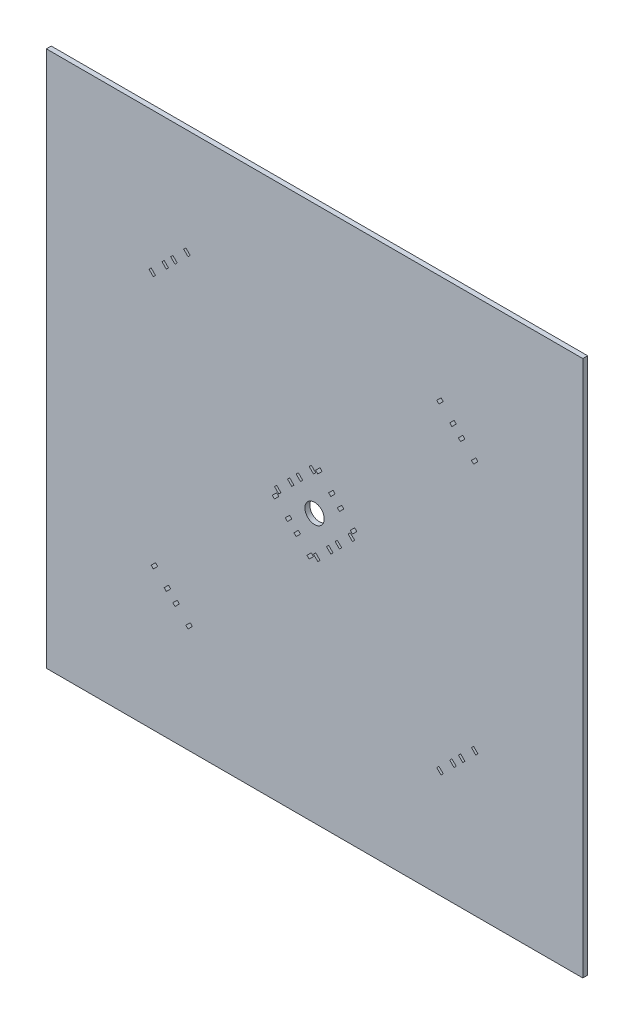
from build123d import *

# Parameters (mm, degrees)
MODEL_W             = 175
MODEL_H             = 175
MODEL_R             = 3.15
BOSS_EXTRUDE1_DEPTH = 1.5875


with BuildPart() as part:
    # Model → Boss-Extrude1 (new body)
    with BuildSketch(Plane.XY):
        with Locations((87.5, 87.5)):
            Rectangle(MODEL_W, MODEL_H)
        with Locations((87.5, 87.5)):
            Circle(MODEL_R, mode=Mode.SUBTRACT)
        Polygon((139.381727984, 47.639087297), (140.795941546, 46.224873734), (140.088834765, 45.517766953), (138.674621202, 46.931980515), align=None, mode=Mode.SUBTRACT)
        Polygon((135.139087297, 43.396446609), (136.553300859, 41.982233047), (135.846194078, 41.275126266), (134.431980515, 42.689339828), align=None, mode=Mode.SUBTRACT)
        Polygon((132.310660172, 40.568019485), (133.724873734, 39.153805922), (133.017766953, 38.446699141), (131.603553391, 39.860912703), align=None, mode=Mode.SUBTRACT)
        Polygon((128.068019485, 36.325378798), (129.482233047, 34.911165235), (128.775126266, 34.204058454), (127.360912703, 35.618272016), align=None, mode=Mode.SUBTRACT)
        Polygon((87.853553391, 76.539844892), (89.267766953, 75.125631329), (88.560660172, 74.418524548), (87.146446609, 75.83273811), align=None, mode=Mode.SUBTRACT)
        Polygon((92.096194078, 80.782485579), (93.51040764, 79.368272016), (92.803300859, 78.661165235), (91.389087297, 80.075378798), align=None, mode=Mode.SUBTRACT)
        Polygon((47.639087297, 35.618272016), (46.224873734, 34.204058454), (45.517766953, 34.911165235), (46.931980515, 36.325378798), align=None, mode=Mode.SUBTRACT)
        Polygon((43.396446609, 39.860912703), (41.982233047, 38.446699141), (41.275126266, 39.153805922), (42.689339828, 40.568019485), align=None, mode=Mode.SUBTRACT)
        Polygon((40.568019485, 42.689339828), (39.153805922, 41.275126266), (38.446699141, 41.982233047), (39.860912703, 43.396446609), align=None, mode=Mode.SUBTRACT)
        Polygon((36.325378798, 46.931980515), (34.911165235, 45.517766953), (34.204058454, 46.224873734), (35.618272016, 47.639087297), align=None, mode=Mode.SUBTRACT)
        Polygon((75.83273811, 86.439339828), (74.418524548, 85.025126266), (73.711417767, 85.732233047), (75.125631329, 87.146446609), align=None, mode=Mode.SUBTRACT)
        Polygon((80.075378798, 82.196699141), (78.661165235, 80.782485579), (77.954058454, 81.48959236), (79.368272016, 82.903805922), align=None, mode=Mode.SUBTRACT)
        Polygon((82.903805922, 79.368272016), (81.48959236, 77.954058454), (80.782485579, 78.661165235), (82.196699141, 80.075378798), align=None, mode=Mode.SUBTRACT)
        Polygon((87.146446609, 75.125631329), (85.732233047, 73.711417767), (85.025126266, 74.418524548), (86.439339828, 75.83273811), align=None, mode=Mode.SUBTRACT)
        Polygon((101.288582233, 89.267766953), (99.874368671, 87.853553391), (99.16726189, 88.560660172), (100.581475452, 89.974873734), align=None, mode=Mode.SUBTRACT)
        Polygon((97.045941546, 93.51040764), (95.631727984, 92.096194078), (94.924621202, 92.803300859), (96.338834765, 94.217514421), align=None, mode=Mode.SUBTRACT)
        Polygon((94.217514421, 96.338834765), (92.803300859, 94.924621202), (92.096194078, 95.631727984), (93.51040764, 97.045941546), align=None, mode=Mode.SUBTRACT)
        Polygon((89.974873734, 100.581475452), (88.560660172, 99.16726189), (87.853553391, 99.874368671), (89.267766953, 101.288582233), align=None, mode=Mode.SUBTRACT)
        Polygon((129.482233047, 140.088834765), (128.068019485, 138.674621202), (127.360912703, 139.381727984), (128.775126266, 140.795941546), align=None, mode=Mode.SUBTRACT)
        Polygon((133.724873734, 135.846194078), (132.310660172, 134.431980515), (131.603553391, 135.139087297), (133.017766953, 136.553300859), align=None, mode=Mode.SUBTRACT)
        Polygon((136.553300859, 133.017766953), (135.139087297, 131.603553391), (134.431980515, 132.310660172), (135.846194078, 133.724873734), align=None, mode=Mode.SUBTRACT)
        Polygon((140.795941546, 128.775126266), (139.381727984, 127.360912703), (138.674621202, 128.068019485), (140.088834765, 129.482233047), align=None, mode=Mode.SUBTRACT)
        Polygon((94.924621202, 83.610912703), (96.338834765, 82.196699141), (95.631727984, 81.48959236), (94.217514421, 82.903805922), align=None, mode=Mode.SUBTRACT)
        Polygon((99.16726189, 87.853553391), (100.581475452, 86.439339828), (99.874368671, 85.732233047), (98.460155108, 87.146446609), align=None, mode=Mode.SUBTRACT)
        Polygon((75.125631329, 89.267766953), (76.539844892, 87.853553391), (75.83273811, 87.146446609), (74.418524548, 88.560660172), align=None, mode=Mode.SUBTRACT)
        Polygon((79.368272016, 93.51040764), (80.782485579, 92.096194078), (80.075378798, 91.389087297), (78.661165235, 92.803300859), align=None, mode=Mode.SUBTRACT)
        Polygon((82.196699141, 96.338834765), (83.610912703, 94.924621202), (82.903805922, 94.217514421), (81.48959236, 95.631727984), align=None, mode=Mode.SUBTRACT)
        Polygon((86.439339828, 100.581475452), (87.853553391, 99.16726189), (87.146446609, 98.460155108), (85.732233047, 99.874368671), align=None, mode=Mode.SUBTRACT)
        Polygon((34.204058454, 130.189339828), (35.618272016, 128.775126266), (34.911165235, 128.068019485), (33.496951673, 129.482233047), align=None, mode=Mode.SUBTRACT)
        Polygon((38.446699141, 134.431980515), (39.860912703, 133.017766953), (39.153805922, 132.310660172), (37.73959236, 133.724873734), align=None, mode=Mode.SUBTRACT)
        Polygon((41.275126266, 137.26040764), (42.689339828, 135.846194078), (41.982233047, 135.139087297), (40.568019485, 136.553300859), align=None, mode=Mode.SUBTRACT)
        Polygon((45.517766953, 141.503048327), (46.931980515, 140.088834765), (46.224873734, 139.381727984), (44.810660172, 140.795941546), align=None, mode=Mode.SUBTRACT)
    extrude(amount=BOSS_EXTRUDE1_DEPTH)


solid = part.part
